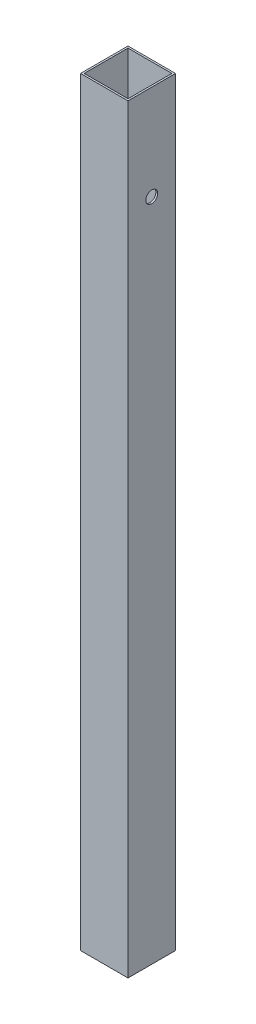
from build123d import *

# Parameters (mm, degrees)
SKETCH1_W           = 25.4
SKETCH1_H           = 25.4
SKETCH1_W_2         = 23.4696
SKETCH1_H_2         = 23.4696
BOSS_EXTRUDE1_DEPTH = 406.4
SKETCH3_R           = 3.175
CUT_EXTRUDE1_DEPTH  = 406.4


with BuildPart() as part:
    # Sketch1 → Boss-Extrude1 (new body)
    with BuildSketch(Plane(origin=(0, 0, 0), x_dir=(1, 0, 0), z_dir=(0, 1, 0))):
        Rectangle(SKETCH1_W, SKETCH1_H)
        Rectangle(SKETCH1_W_2, SKETCH1_H_2, mode=Mode.SUBTRACT)
    extrude(amount=BOSS_EXTRUDE1_DEPTH)

    # Sketch3 → Cut-Extrude1 (cut)
    with BuildSketch(Plane.ZY.offset(12.7)):
        with Locations((0, 355.6)):
            Circle(SKETCH3_R)
    extrude(amount=-CUT_EXTRUDE1_DEPTH, mode=Mode.SUBTRACT)


solid = part.part
